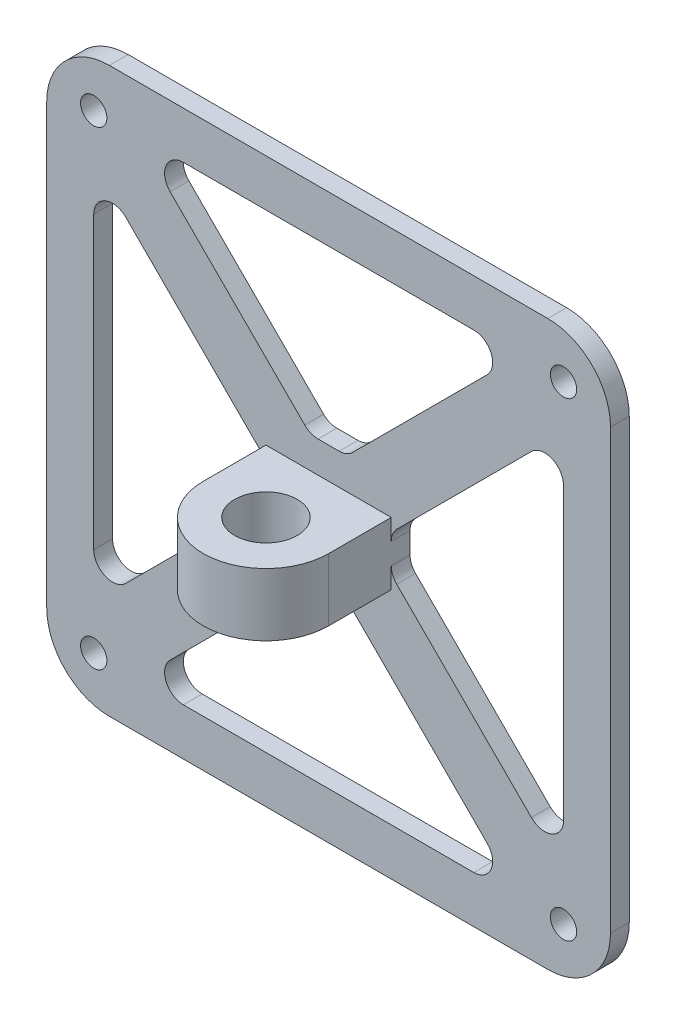
from build123d import *

# Parameters (mm, degrees)
ESQUISSE1_R             = 2.1
BOSS_EXTRU_1_DEPTH      = 3
BOSS_EXTRU_2_START      = -50
ESQUISSE4_R             = 5
BOSS_EXTRU_2_DEPTH      = 10
ENL_V_MAT_EXTRU_1_DEPTH = 10


with BuildPart() as part:
    # Esquisse1 → Boss.-Extru.1 (new body)
    with BuildSketch(Plane.XY):
        with BuildLine():
            Line((-35, -45), (35, -45))
            ThreePointArc((35, -45), (42.071067812, -42.071067812), (45, -35))
            Line((45, -35), (45, 35))
            ThreePointArc((45, 35), (42.071067812, 42.071067812), (35, 45))
            Line((35, 45), (-35, 45))
            ThreePointArc((-35, 45), (-42.071067812, 42.071067812), (-45, 35))
            Line((-45, 35), (-45, -35))
            ThreePointArc((-45, -35), (-42.071067812, -42.071067812), (-35, -45))
        make_face()
        with Locations((-37.5, 37.5)):
            Circle(ESQUISSE1_R, mode=Mode.SUBTRACT)
        with Locations((37.5, 37.5)):
            Circle(ESQUISSE1_R, mode=Mode.SUBTRACT)
        with Locations((37.5, -37.5)):
            Circle(ESQUISSE1_R, mode=Mode.SUBTRACT)
        with Locations((-37.5, -37.5)):
            Circle(ESQUISSE1_R, mode=Mode.SUBTRACT)
    extrude(amount=BOSS_EXTRU_1_DEPTH)

    # Esquisse4 → Boss.-Extru.2 (add)
    with BuildSketch(Plane(origin=(0, 45, 123.316242038), x_dir=(1, 0, 0), z_dir=(0, 1, 0)).offset(BOSS_EXTRU_2_START)):
        with BuildLine():
            Line((10, 120.316242038), (10, 110.316242038))
            ThreePointArc((10, 110.316242038), (0, 100.316242038), (-10, 110.316242038))
            Line((-10, 110.316242038), (-10, 120.316242038))
            Line((-10, 120.316242038), (10, 120.316242038))
        make_face()
        with Locations((0, 110.316242038)):
            Circle(ESQUISSE4_R, mode=Mode.SUBTRACT)
    extrude(amount=BOSS_EXTRU_2_DEPTH)

    # Esquisse5 → Enlèv. mat.-Extru.1 (cut)
    with BuildSketch(Plane.XY.offset(3)):
        with BuildLine():
            Line((-23.186291501, 37.5), (23.186291501, 37.5))
            ThreePointArc((23.186291501, 37.5), (25.957930099, 35.648050297), (25.307611845, 32.378679656))
            Line((25.307611845, 32.378679656), (3.807611845, 10.878679656))
            ThreePointArc((3.807611845, 10.878679656), (2.834341798, 10.228361402), (1.686291501, 10))
            Line((1.686291501, 10), (-1.686291501, 10))
            ThreePointArc((-1.686291501, 10), (-2.834341798, 10.228361402), (-3.807611845, 10.878679656))
            Line((-3.807611845, 10.878679656), (-25.307611845, 32.378679656))
            ThreePointArc((-25.307611845, 32.378679656), (-25.957930099, 35.648050297), (-23.186291501, 37.5))
        make_face()
        with BuildLine():
            Line((-32.378679656, -25.307611845), (-10.878679656, -3.807611845))
            ThreePointArc((-10.878679656, -3.807611845), (-10.228361402, -2.834341798), (-10, -1.686291501))
            Line((-10, -1.686291501), (-10, 1.686291501))
            ThreePointArc((-10, 1.686291501), (-10.228361402, 2.834341798), (-10.878679656, 3.807611845))
            Line((-10.878679656, 3.807611845), (-32.378679656, 25.307611845))
            ThreePointArc((-32.378679656, 25.307611845), (-35.648050297, 25.957930099), (-37.5, 23.186291501))
            Line((-37.5, 23.186291501), (-37.5, -23.186291501))
            ThreePointArc((-37.5, -23.186291501), (-35.648050297, -25.957930099), (-32.378679656, -25.307611845))
        make_face()
        with BuildLine():
            Line((32.378679656, 25.307611845), (10.878679656, 3.807611845))
            ThreePointArc((10.878679656, 3.807611845), (10.228361402, 2.834341798), (10, 1.686291501))
            Line((10, 1.686291501), (10, -1.686291501))
            ThreePointArc((10, -1.686291501), (10.228361402, -2.834341798), (10.878679656, -3.807611845))
            Line((10.878679656, -3.807611845), (32.378679656, -25.307611845))
            ThreePointArc((32.378679656, -25.307611845), (35.648050297, -25.957930099), (37.5, -23.186291501))
            Line((37.5, -23.186291501), (37.5, 23.186291501))
            ThreePointArc((37.5, 23.186291501), (35.648050297, 25.957930099), (32.378679656, 25.307611845))
        make_face()
        with BuildLine():
            Line((23.186291501, -37.5), (-23.186291501, -37.5))
            ThreePointArc((-23.186291501, -37.5), (-25.957930099, -35.648050297), (-25.307611845, -32.378679656))
            Line((-25.307611845, -32.378679656), (-3.807611845, -10.878679656))
            ThreePointArc((-3.807611845, -10.878679656), (-2.834341798, -10.228361402), (-1.686291501, -10))
            Line((-1.686291501, -10), (1.686291501, -10))
            ThreePointArc((1.686291501, -10), (2.834341798, -10.228361402), (3.807611845, -10.878679656))
            Line((3.807611845, -10.878679656), (25.307611845, -32.378679656))
            ThreePointArc((25.307611845, -32.378679656), (25.957930099, -35.648050297), (23.186291501, -37.5))
        make_face()
    extrude(amount=-ENL_V_MAT_EXTRU_1_DEPTH, mode=Mode.SUBTRACT)


solid = part.part
